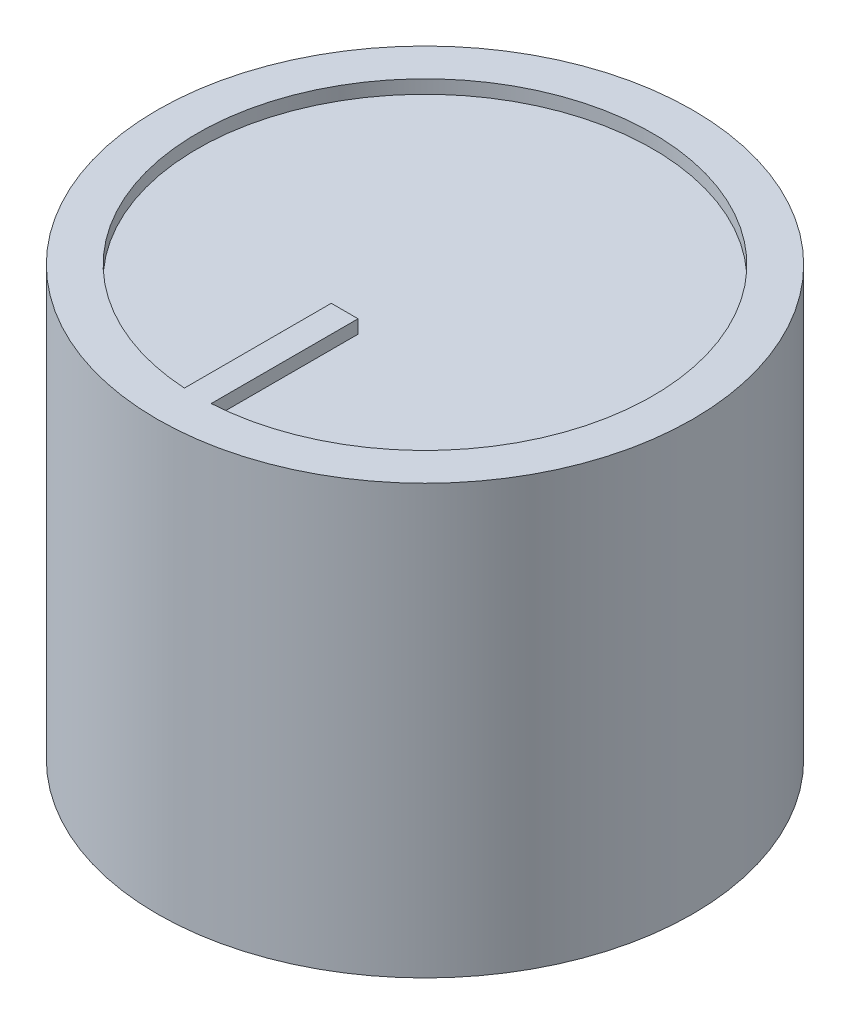
from build123d import *

# Parameters (mm, degrees)
SKETCH_2_W      = 1
SKETCH_2_H      = 5.5
EXTRUDE_1_DEPTH = 0.5


with BuildPart() as part:
    # Эскиз1 → Повернуть1 (revolve)
    with BuildSketch(Plane(origin=(0, 0, 0), x_dir=(0, 0, -1), z_dir=(1, 0, 0))):
        Polygon((0, 0), (-3, 0), (-3, -9.5), (-4.5, -9.5), (-4.5, -2), (-6, -2), (-6, -13), (-10, -13), (-10, 3), (-8.5, 3), (-8.5, 2.5), (0, 2.5), align=None)
    revolve(axis=Axis((0, 2.5, 0), (0, -1, 0)))

    # Эскиз2 → Бобышка-Вытянуть1 (add)
    with BuildSketch(Plane(origin=(0, 2.5, 0), x_dir=(1, 0, 0), z_dir=(0, 1, 0))):
        with Locations((0, -5.75)):
            Rectangle(SKETCH_2_W, SKETCH_2_H)
    extrude(amount=EXTRUDE_1_DEPTH)


solid = part.part
